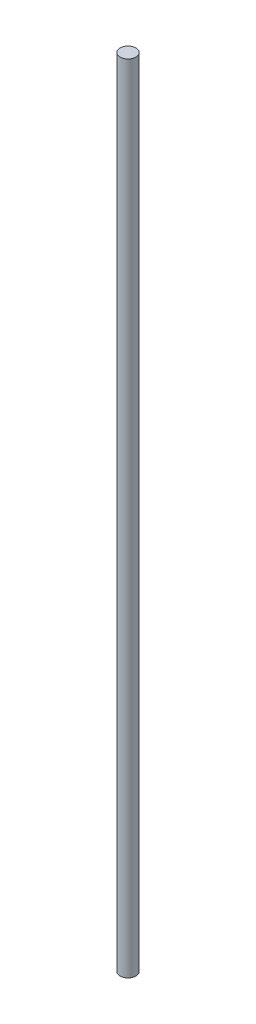
from build123d import *

# Parameters (mm, degrees)
SKETCH1_R           = 4
BOSS_EXTRUDE1_DEPTH = 400


with BuildPart() as part:
    # Sketch1 → Boss-Extrude1 (new body)
    with BuildSketch(Plane(origin=(0, 0, 0), x_dir=(1, 0, 0), z_dir=(0, 1, 0))):
        Circle(SKETCH1_R)
    extrude(amount=BOSS_EXTRUDE1_DEPTH)


solid = part.part
